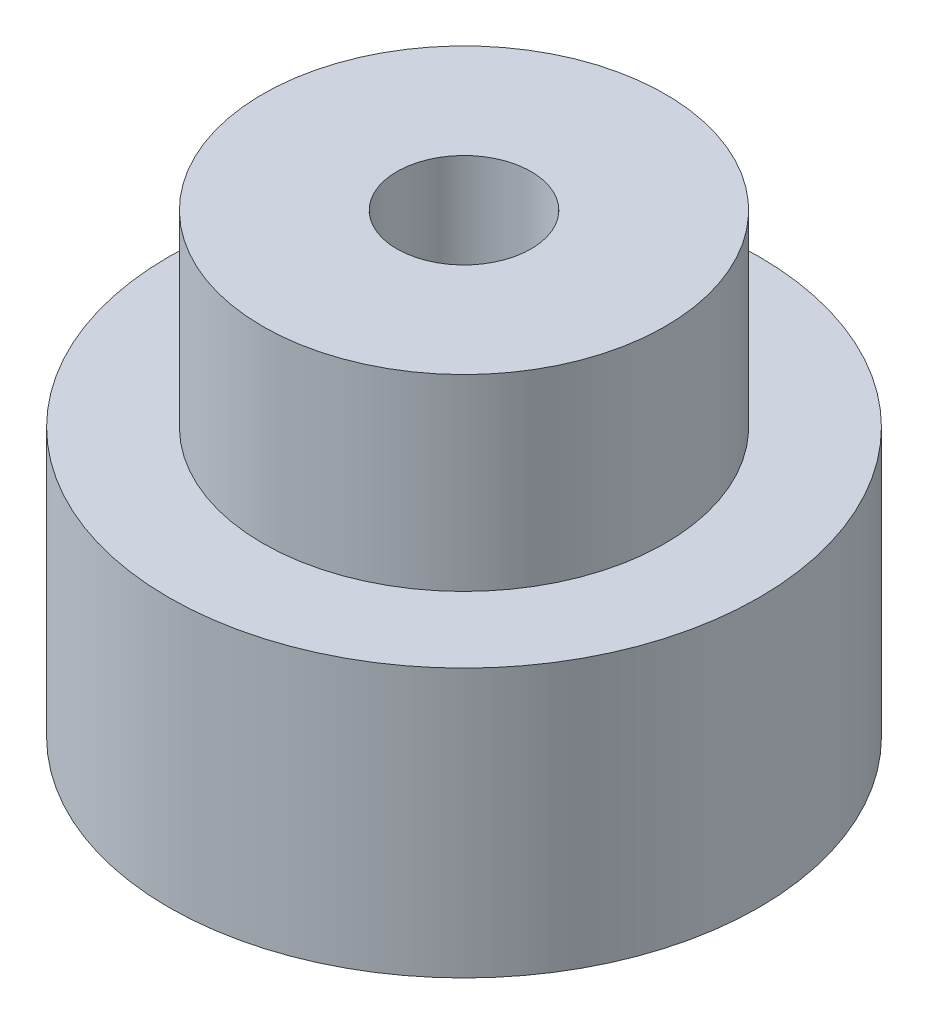
from build123d import *

# Parameters (mm, degrees)
SKETCH1_R               = 11
BOSS_EXTRUDE1_DEPTH     = 10
SKETCH1_3_R             = 7.5
BOSS_EXTRUDE2_DEPTH     = 7
CUT_EXTRUDE1_DEPTH      = 10
CUT_EXTRUDE1_DEPTH_BACK = 11
SKETCH1_4_R             = 2.5


with BuildPart() as part:
    # Sketch1 → Boss-Extrude1 (new body)
    with BuildSketch(Plane(origin=(0, 0, 0), x_dir=(1, 0, 0), z_dir=(0, 1, 0))):
        Circle(SKETCH1_R)
    extrude(amount=-BOSS_EXTRUDE1_DEPTH)

    # Sketch1_3 → Boss-Extrude2 (add)
    with BuildSketch(Plane(origin=(0, 0, 0), x_dir=(1, 0, 0), z_dir=(0, 1, 0))):
        Circle(SKETCH1_3_R)
    extrude(amount=BOSS_EXTRUDE2_DEPTH)

    # Sketch1_4 → Cut-Extrude1 (cut, two sides: drawn at the far end of the back side and taken through both)
    with BuildSketch(Plane(origin=(0, 0, 0), x_dir=(1, 0, 0), z_dir=(0, 1, 0)).offset(-CUT_EXTRUDE1_DEPTH_BACK)):
        Circle(SKETCH1_4_R)
    extrude(amount=CUT_EXTRUDE1_DEPTH + CUT_EXTRUDE1_DEPTH_BACK, mode=Mode.SUBTRACT)


solid = part.part
